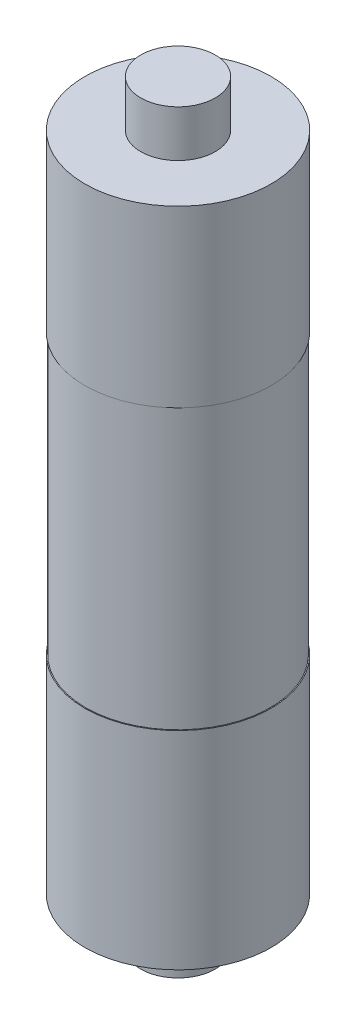
from build123d import *

# Parameters (mm, degrees)
CROQUIS1_R              = 10
SALIENTE_EXTRUIR1_DEPTH = 71
CROQUIS3_W              = 0.1
CROQUIS3_H              = 30
CROQUIS4_R              = 4
SALIENTE_EXTRUIR2_DEPTH = 5
CROQUIS5_R              = 4
SALIENTE_EXTRUIR3_DEPTH = 5


with BuildPart() as part:
    # Croquis1 → Saliente-Extruir1 (new body)
    with BuildSketch(Plane(origin=(0, 0, 0), x_dir=(1, 0, 0), z_dir=(0, 1, 0))):
        Circle(CROQUIS1_R)
    extrude(amount=SALIENTE_EXTRUIR1_DEPTH)

    # Croquis3 → Cortar-Revolución1 (revolve, cut)
    with BuildSketch(Plane(origin=(0, 0, 0), x_dir=(0, 0, -1), z_dir=(1, 0, 0))):
        with Locations((9.95, 37.25)):
            Rectangle(CROQUIS3_W, CROQUIS3_H)
    revolve(axis=Axis((0, 71, 0), (0, -1, 0)), mode=Mode.SUBTRACT)

    # Croquis4 → Saliente-Extruir2 (add)
    with BuildSketch(Plane(origin=(0, 0, 0), x_dir=(-1, 0, 0), z_dir=(0, -1, 0))):
        Circle(CROQUIS4_R)
    extrude(amount=SALIENTE_EXTRUIR2_DEPTH)

    # Croquis5 → Saliente-Extruir3 (add)
    with BuildSketch(Plane(origin=(0, 71, 0), x_dir=(1, 0, 0), z_dir=(0, 1, 0))):
        Circle(CROQUIS5_R)
    extrude(amount=SALIENTE_EXTRUIR3_DEPTH)


solid = part.part
